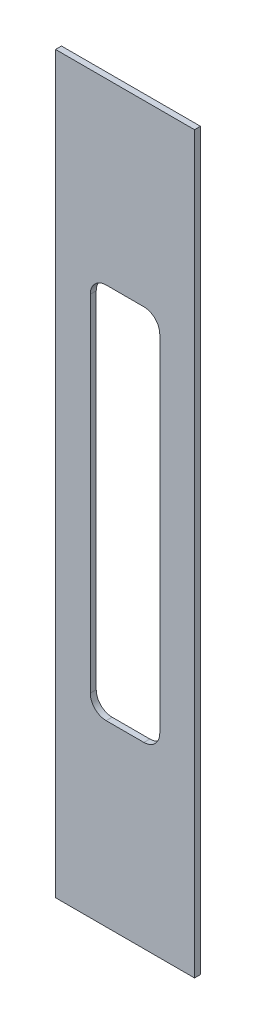
from build123d import *

# Parameters (mm, degrees)
SZKIC3_W                    = 70
SZKIC3_H                    = 370
DODANIE_WYCI_GNI_CIE1_DEPTH = 1.5
WYTNIJ_WYCI_GNI_CIE1_REACH  = 5


with BuildPart() as part:
    # Szkic3 → Dodanie-wyciągnięcie1 (new body, symmetric)
    with BuildSketch(Plane(origin=(0, 0, 113), x_dir=(-1, 0, 0), z_dir=(0, 0, -1))):
        with Locations((95, 0)):
            Rectangle(SZKIC3_W, SZKIC3_H)
    extrude(amount=DODANIE_WYCI_GNI_CIE1_DEPTH, both=True)

    # Szkic4 → Wytnij-wyciągnięcie1 (cut, up to next)
    with BuildSketch(Plane.XY.offset(114.5), mode=Mode.PRIVATE) as wytnij_wyci_gni_cie1_sk1:
        with BuildLine():
            Line((-85.5, -95), (-104.5, -95))
            ThreePointArc((-104.5, -95), (-110.156854249, -92.656854249), (-112.5, -87))
            Line((-112.5, -87), (-112.5, 87))
            ThreePointArc((-112.5, 87), (-110.156854249, 92.656854249), (-104.5, 95))
            Line((-104.5, 95), (-85.5, 95))
            ThreePointArc((-85.5, 95), (-79.843145751, 92.656854249), (-77.5, 87))
            Line((-77.5, 87), (-77.5, -87))
            ThreePointArc((-77.5, -87), (-79.843145751, -92.656854249), (-85.5, -95))
        make_face()
    wytnij_wyci_gni_cie1_tool1 = extrude(wytnij_wyci_gni_cie1_sk1.sketch, amount=-WYTNIJ_WYCI_GNI_CIE1_REACH, mode=Mode.PRIVATE) & part.part
    add(wytnij_wyci_gni_cie1_tool1.solids().sort_by_distance((-95, 0, 114.5))[0], mode=Mode.SUBTRACT)


solid = part.part
